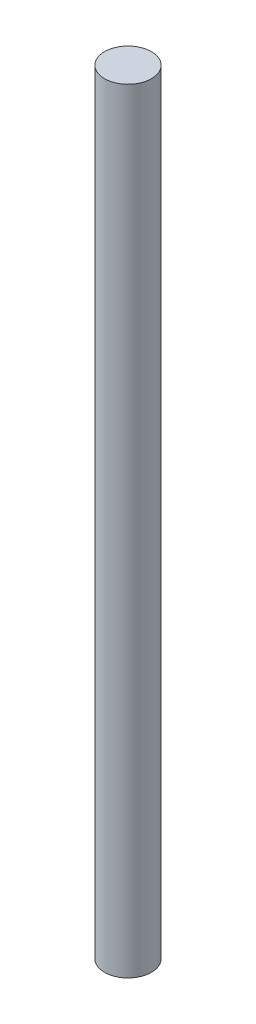
from build123d import *

# Parameters (mm, degrees)
CROQUIS1_R              = 3.15
SALIENTE_EXTRUIR1_DEPTH = 104


with BuildPart() as part:
    # Croquis1 → Saliente-Extruir1 (new body)
    with BuildSketch(Plane(origin=(0, 0, 0), x_dir=(1, 0, 0), z_dir=(0, 1, 0))):
        Circle(CROQUIS1_R)
    extrude(amount=SALIENTE_EXTRUIR1_DEPTH)


solid = part.part
